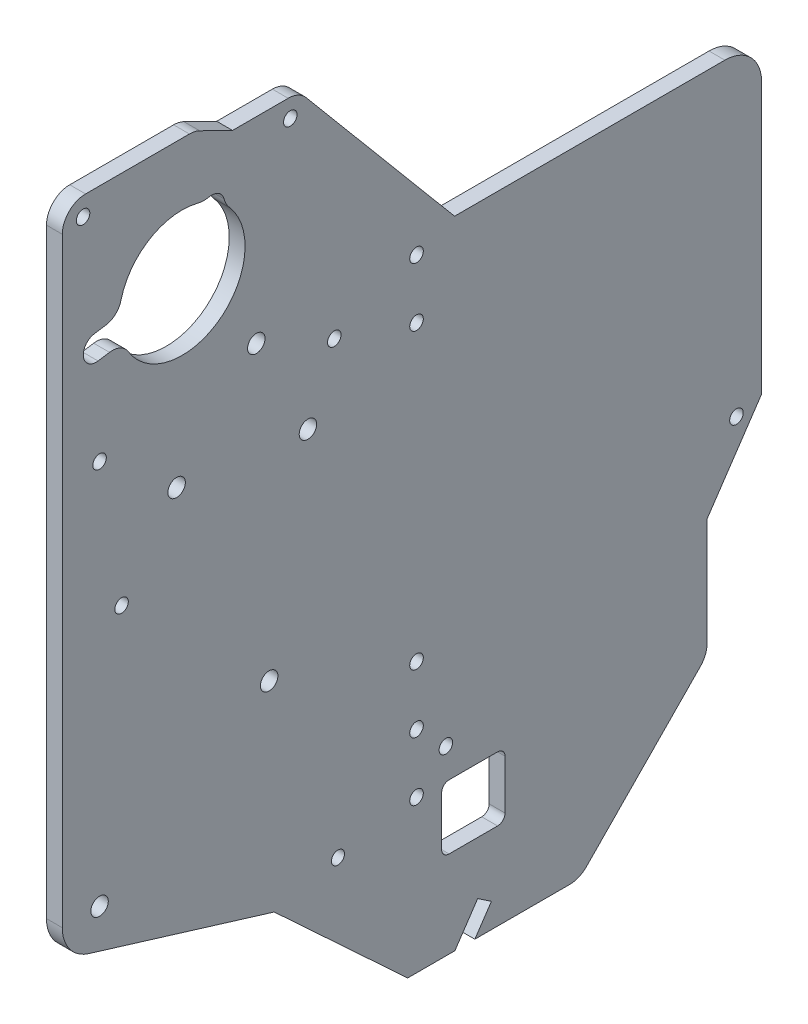
from build123d import *

# Parameters (mm, degrees)
SKETCH2_R           = 2.38125
SKETCH2_R_2         = 1.850000002
SKETCH2_R_3         = 1.85
SKETCH2_R_4         = 1.778
SKETCH2_R_5         = 1.8415
BOSS_EXTRUDE1_DEPTH = 4.318


with BuildPart() as part:
    # Sketch2 → Boss-Extrude1 (new body)
    with BuildSketch(Plane(origin=(0, 0, 0), x_dir=(0, 0, -1), z_dir=(1, 0, 0))):
        with BuildLine():
            Line((-115.889220019, 171.954), (-189.580583869, 171.954))
            Line((-189.580583869, 171.954), (-230.07024685, 220.207701322))
            ThreePointArc((-230.07024685, 220.207701322), (-232.251003102, 221.881054448), (-234.934629064, 222.476))
            Line((-234.934629064, 222.476), (-250.119258716, 222.476))
            Line((-250.119258716, 222.476), (-259.069094553, 226.862369804))
            ThreePointArc((-259.069094553, 226.862369804), (-260.42931468, 227.346249494), (-261.863679558, 227.510370624))
            Line((-261.863679558, 227.510370624), (-290.181258716, 227.510370624))
            ThreePointArc((-290.181258716, 227.510370624), (-294.671386777, 225.650498684), (-296.531258716, 221.160370624))
            Line((-296.531258716, 221.160370624), (-296.531258716, 57.430370624))
            ThreePointArc((-296.531258716, 57.430370624), (-294.538216111, 51.386662581), (-289.341021135, 47.714089896))
            Line((-289.341021135, 47.714089896), (-238.759677477, 32.254))
            Line((-238.759677477, 32.254), (-202.359677477, -1.524))
            Line((-202.359677477, -1.524), (-189.491289728, -1.524))
            Line((-189.491289728, -1.524), (-183.278653236, 7.686612375))
            Line((-183.278653236, 7.686612375), (-179.541351859, 5.165770766))
            Line((-179.541351859, 5.165770766), (-184.053659217, -1.524))
            Line((-184.053659217, -1.524), (-158.188157254, -1.524))
            ThreePointArc((-158.188157254, -1.524), (-155.726821474, -1.027573796), (-153.650327137, 0.384086243))
            Line((-153.650327137, 0.384086243), (-122.571428599, 32.134086243))
            ThreePointArc((-122.571428599, 32.134086243), (-121.22972977, 34.177325496), (-120.759258716, 36.576))
            Line((-120.759258716, 36.576), (-120.759258716, 66.032))
            Line((-120.759258716, 66.032), (-105.889220019, 88.077738973))
            Line((-105.889220019, 88.077738973), (-105.889220019, 161.954))
            ThreePointArc((-105.889220019, 161.954), (-108.818152207, 169.025067812), (-115.889220019, 171.954))
        make_face()
        with Locations((-243.629318942, 168.931188955)):
            Circle(SKETCH2_R, mode=Mode.SUBTRACT)
        with Locations((-286.371258716, 57.430370624)):
            Circle(SKETCH2_R, mode=Mode.SUBTRACT)
        with Locations((-229.557259723, 141.660587995)):
            Circle(SKETCH2_R, mode=Mode.SUBTRACT)
        with Locations((-112.732319415, 86.216867446)):
            Circle(SKETCH2_R_2, mode=Mode.SUBTRACT)
        with Locations((-199.955990958, 72)):
            Circle(SKETCH2_R_3, mode=Mode.SUBTRACT)
        with Locations((-199.955990958, 152)):
            Circle(SKETCH2_R_3, mode=Mode.SUBTRACT)
        with Locations((-199.955990958, 168)):
            Circle(SKETCH2_R_3, mode=Mode.SUBTRACT)
        with Locations((-221.371258716, 36.430370624)):
            Circle(SKETCH2_R_4, mode=Mode.SUBTRACT)
        with Locations((-240.13308557, 87.518200818)):
            Circle(SKETCH2_R, mode=Mode.SUBTRACT)
        with Locations((-199.955990958, 40)):
            Circle(SKETCH2_R_3, mode=Mode.SUBTRACT)
        with Locations((-191.955990958, 48)):
            Circle(SKETCH2_R_3, mode=Mode.SUBTRACT)
        with Locations((-199.955990958, 56)):
            Circle(SKETCH2_R_3, mode=Mode.SUBTRACT)
        with Locations((-280.371258716, 125.430370624)):
            Circle(SKETCH2_R_5, mode=Mode.SUBTRACT)
        with Locations((-222.371258716, 159.430370624)):
            Circle(SKETCH2_R_5, mode=Mode.SUBTRACT)
        with Locations((-286.371258716, 162.430370624)):
            Circle(SKETCH2_R_5, mode=Mode.SUBTRACT)
        with Locations((-265.366688027, 145.789251152)):
            Circle(SKETCH2_R, mode=Mode.SUBTRACT)
        with Locations((-234.371258716, 217.430370624)):
            Circle(SKETCH2_R_5, mode=Mode.SUBTRACT)
        with Locations((-290.871258716, 222.430370624)):
            Circle(SKETCH2_R_5, mode=Mode.SUBTRACT)
        with BuildLine():
            Line((-287.829388906, 193.285058383), (-284.701870397, 193.761043975))
            ThreePointArc((-284.701870397, 193.761043975), (-282.046244193, 195.026852777), (-280.537562028, 197.552422136))
            ThreePointArc((-280.537562028, 197.552422136), (-272.673389463, 208.141620232), (-259.619652409, 210.032724503))
            ThreePointArc((-259.619652409, 210.032724503), (-258.077063161, 209.822786209), (-256.52721589, 209.969854606))
            ThreePointArc((-256.52721589, 209.969854606), (-253.968498332, 209.529478199), (-252.417164512, 207.447572749))
            ThreePointArc((-252.417164512, 207.447572749), (-251.846450969, 205.99914542), (-250.960720569, 204.718857431))
            ThreePointArc((-250.960720569, 204.718857431), (-253.704909037, 179.546702846), (-278.544971255, 184.459873489))
            ThreePointArc((-278.544971255, 184.459873489), (-280.736689043, 186.422268863), (-283.64864912, 186.840731487))
            Line((-283.64864912, 186.840731487), (-286.776167629, 186.364745894))
            ThreePointArc((-286.776167629, 186.364745894), (-290.762934512, 189.2982915), (-287.829388906, 193.285058383))
        make_face(mode=Mode.SUBTRACT)
        with BuildLine():
            Line((-177.859990958, 39.62), (-191.067990958, 39.62))
            ThreePointArc((-191.067990958, 39.62), (-192.504831938, 39.024840979), (-193.099990958, 37.588))
            Line((-193.099990958, 37.588), (-193.099990958, 24.158))
            ThreePointArc((-193.099990958, 24.158), (-192.504831938, 22.721159021), (-191.067990958, 22.126))
            Line((-191.067990958, 22.126), (-177.859990958, 22.126))
            ThreePointArc((-177.859990958, 22.126), (-176.423149979, 22.721159021), (-175.827990958, 24.158))
            Line((-175.827990958, 24.158), (-175.827990958, 37.588))
            ThreePointArc((-175.827990958, 37.588), (-176.423149979, 39.024840979), (-177.859990958, 39.62))
        make_face(mode=Mode.SUBTRACT)
    extrude(amount=BOSS_EXTRUDE1_DEPTH)


solid = part.part
